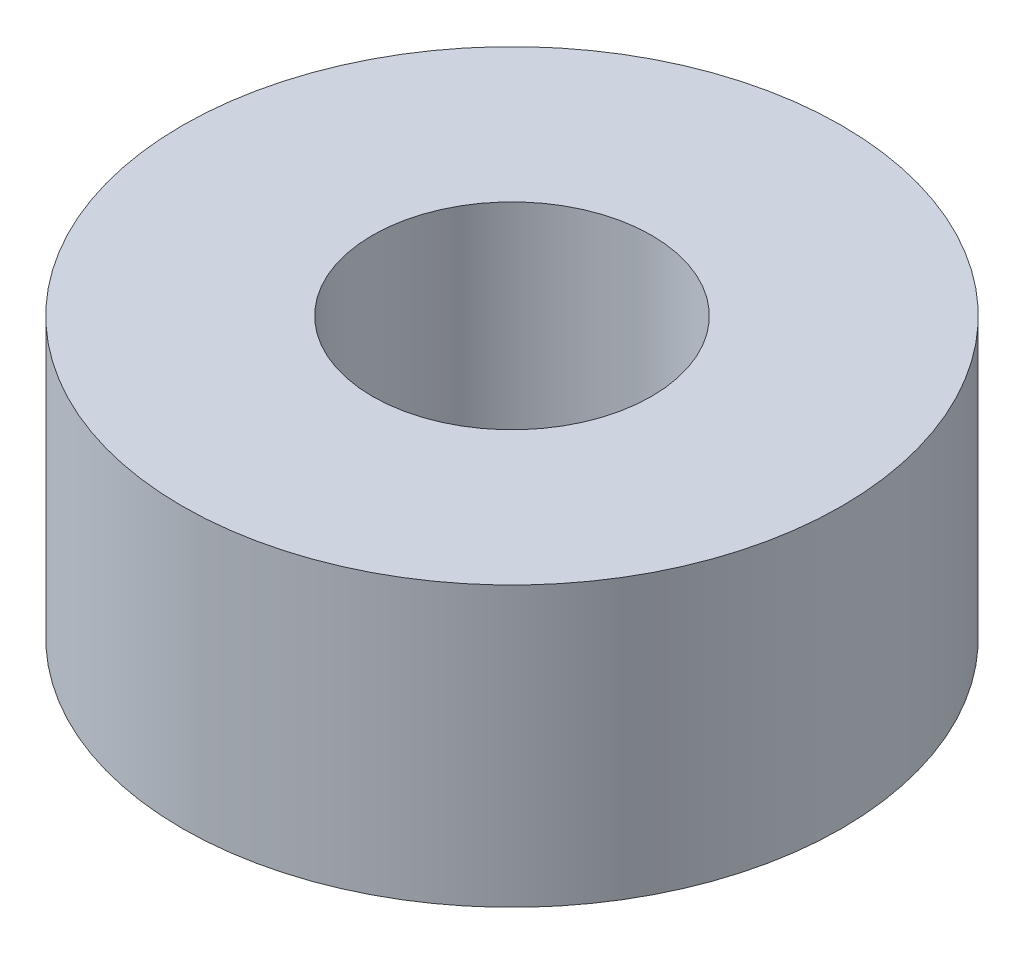
from build123d import *

# Parameters (mm, degrees)
SKETCH1_R           = 7.5
SKETCH1_R_2         = 3.175
BOSS_EXTRUDE1_DEPTH = 6.35


with BuildPart() as part:
    # Sketch1 → Boss-Extrude1 (new body)
    with BuildSketch(Plane(origin=(0, 0, 0), x_dir=(1, 0, 0), z_dir=(0, 1, 0))):
        Circle(SKETCH1_R)
        Circle(SKETCH1_R_2, mode=Mode.SUBTRACT)
    extrude(amount=BOSS_EXTRUDE1_DEPTH)


solid = part.part
